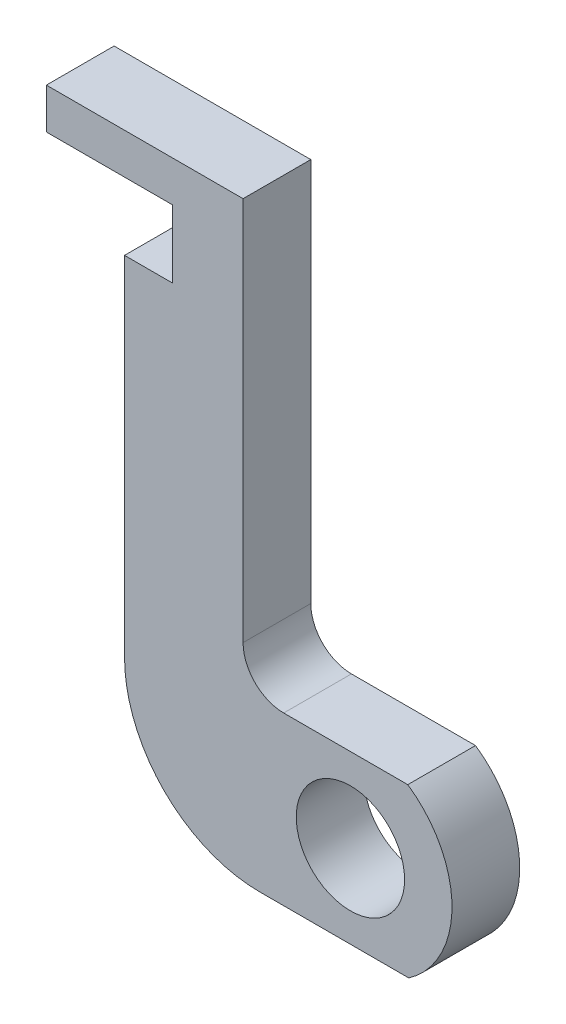
from build123d import *

# Parameters (mm, degrees)
SKETCH_1_R      = 4
EXTRUDE_1_DEPTH = 5


with BuildPart() as part:
    # 草图1 → 凸台-拉伸1 (new body)
    with BuildSketch(Plane.XY):
        with BuildLine():
            Line((-7.924938012, 37.574342627), (-22.446516876, 37.574342627))
            Line((-22.446516876, 37.574342627), (-22.446516876, 34.574342627))
            Line((-22.446516876, 34.574342627), (-13.144515754, 34.574342627))
            Line((-13.144515754, 34.574342627), (-13.144515754, 29.574342627))
            Line((-13.144515754, 29.574342627), (-16.675920201, 29.574342627))
            Line((-16.675920201, 29.574342627), (-16.675920201, 3.864736877))
            ThreePointArc((-16.675920201, 3.864736877), (-13.746988013, -3.206330935), (-6.675920201, -6.135263123))
            Line((-6.675920201, -6.135263123), (4.313762442, -6.135263123))
            ThreePointArc((4.313762442, -6.135263123), (7.499853762, 0.046835335), (4.2368016, 6.188659968))
            Line((4.2368016, 6.188659968), (-4.924938012, 6.188659968))
            ThreePointArc((-4.924938012, 6.188659968), (-7.046258356, 7.067339624), (-7.924938012, 9.188659968))
            Line((-7.924938012, 9.188659968), (-7.924938012, 37.574342627))
        make_face()
        Circle(SKETCH_1_R, mode=Mode.SUBTRACT)
    extrude(amount=EXTRUDE_1_DEPTH)


solid = part.part
